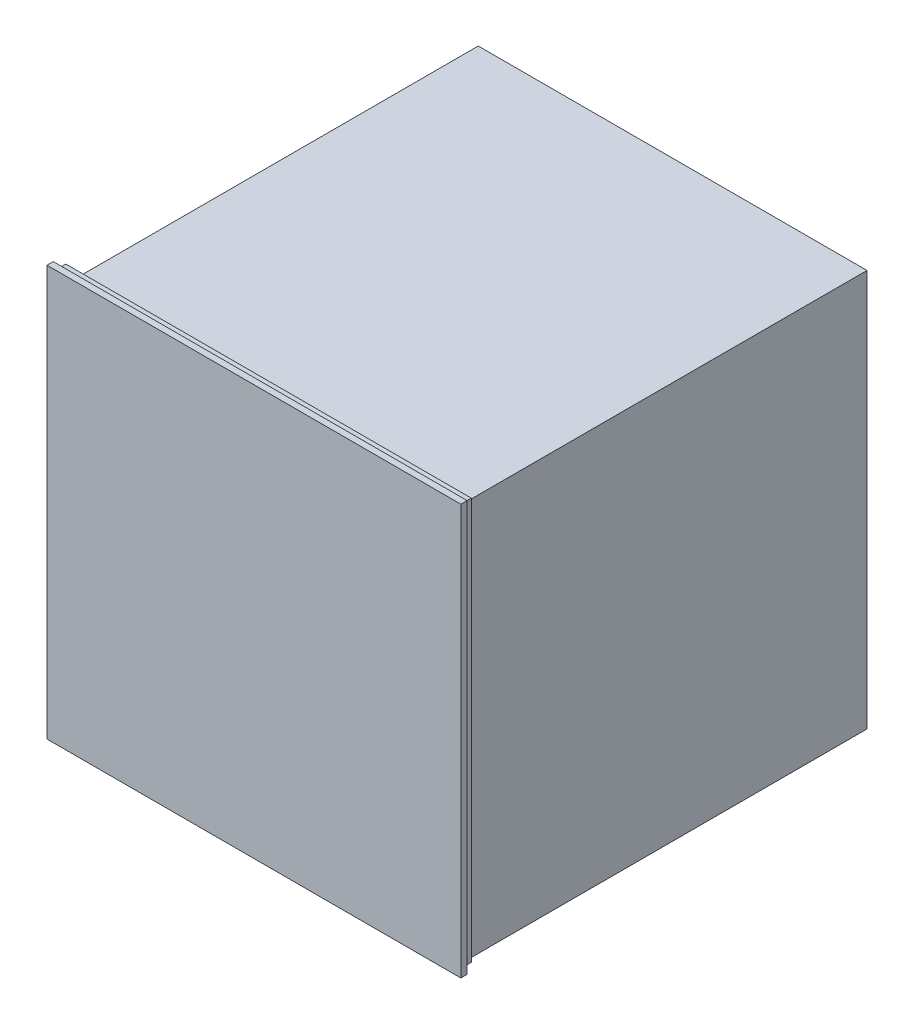
from build123d import *

# Parameters (mm, degrees)
SKETCH_1_W      = 582
SKETCH_1_H      = 577
EXTRUDE_1_DEPTH = 12
SKETCH_2_W      = 558
SKETCH_2_H      = 570
EXTRUDE_2_DEPTH = 580
SKETCH_3_W      = 594
SKETCH_3_H      = 589
EXTRUDE_3_DEPTH = 9


with BuildPart() as part:
    # Эскиз1 → Бобышка-Вытянуть1 (new body)
    with BuildSketch(Plane.XY):
        Rectangle(SKETCH_1_W, SKETCH_1_H)
    extrude(amount=EXTRUDE_1_DEPTH)

    # Эскиз2 → Бобышка-Вытянуть2 (add)
    with BuildSketch(Plane(origin=(0, 0, 0), x_dir=(-1, 0, 0), z_dir=(0, 0, -1))):
        with Locations((0, -9.5)):
            Rectangle(SKETCH_2_W, SKETCH_2_H)
    extrude(amount=EXTRUDE_2_DEPTH)

    # Эскиз3 → Бобышка-Вытянуть3 (add)
    with BuildSketch(Plane.XY.offset(12)):
        Rectangle(SKETCH_3_W, SKETCH_3_H)
    extrude(amount=EXTRUDE_3_DEPTH)


solid = part.part
